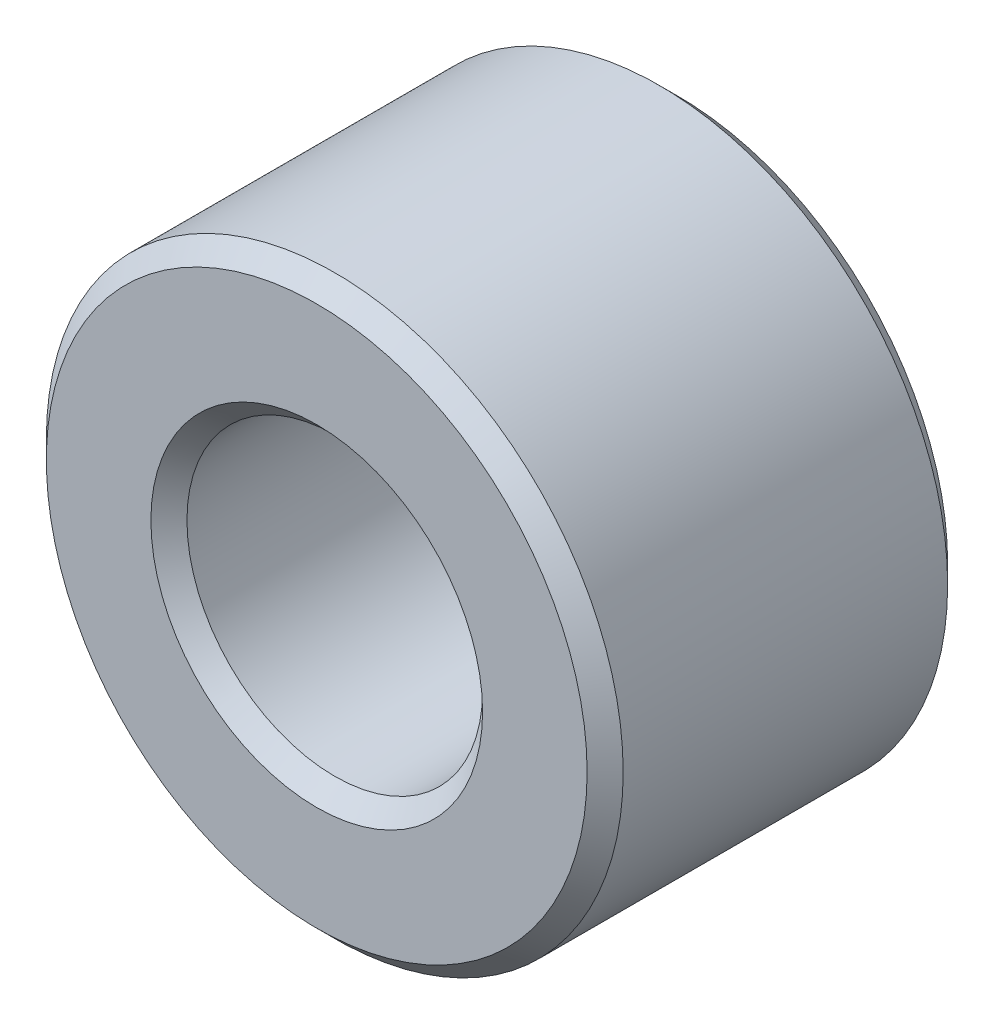
from build123d import *

# Parameters (mm, degrees)
SKETCH1_R      = 4
SKETCH1_R_2    = 2.05
EXTRUDE1_DEPTH = 5
CHAMFER2_SIZE  = 0.25


with BuildPart() as part:
    # Sketch1 → Extrude1 (new body)
    with BuildSketch(Plane.XY):
        Circle(SKETCH1_R)
        Circle(SKETCH1_R_2, mode=Mode.SUBTRACT)
    extrude(amount=EXTRUDE1_DEPTH)

    # Chamfer2
    chamfer2_edges = [part.edges().sort_by_distance(p)[0] for p in [
        (-4, 0, 0),
        (-4, 0, 5),
        (-2.05, 0, 0),
        (-2.05, 0, 5),
    ]]
    chamfer(chamfer2_edges, length=CHAMFER2_SIZE)


solid = part.part
